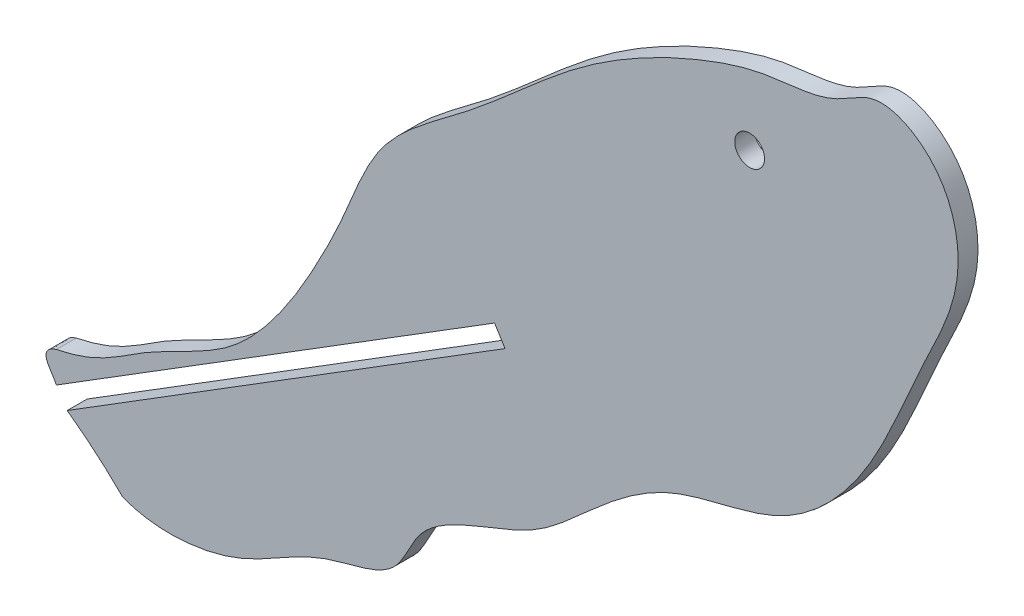
from build123d import *

# Parameters (mm, degrees)
SKETCH1_R           = 2.38125
BOSS_EXTRUDE1_DEPTH = 3.175
CUT_EXTRUDE1_DEPTH  = 3.175


with BuildPart() as part:
    # Sketch1 → Boss-Extrude1 (new body)
    with BuildSketch(Plane.XY):
        with BuildLine():
            Line((40.768145846, 184.453070522), (114.077670793, 230.086665302))
            Line((114.077670793, 230.086665302), (115.755527017, 227.39122035))
            Line((115.755527017, 227.39122035), (43.521756826, 182.427259654))
            add(Edge.make_bspline(
                [(43.521756826, 182.427259654), (44.788750383, 181.76328753), (48.126533854, 180.605526569), (53.705045382, 175.728575889), (63.322367412, 174.351807674), (75.455253783, 177.048714089), (85.407788399, 184.743599328), (98.380090093, 186.107930878), (101.467051899, 195.524505013), (109.919319881, 200.514587774), (120.665380591, 203.617021345), (130.41927408, 213.061934574), (142.549134866, 222.570268935), (160.393689469, 224.081902494), (174.64130148, 238.852254234), (181.053723681, 256.586171695), (190.156058618, 272.865915288), (186.171272479, 287.724417804), (175.242212468, 293.103052821), (167.541303275, 286.786726967), (157.728162565, 286.776771149), (143.796374698, 282.153767947), (126.785607672, 272.999703707), (111.702283177, 257.849735431), (95.369574235, 247.282489302), (90.600838496, 233.821235853), (85.069000572, 222.63671104), (79.332350325, 213.030247768), (70.563493008, 203.671709206), (58.088145357, 198.920146383), (49.8665511, 191.787864635), (36.752245231, 190.436464275), (39.518833147, 185.745298556), (40.768145846, 184.453070522)],
                knots=[0, 0, 0, 0, 0.010738041, 0.027613768, 0.05370555, 0.080470068, 0.119119449, 0.14868445, 0.166041763, 0.187193333, 0.219521226, 0.249444867, 0.287922407, 0.333236135, 0.377488775, 0.432665243, 0.47672388, 0.512866446, 0.536093959, 0.553131728, 0.581565299, 0.607650885, 0.663372441, 0.724739812, 0.769453903, 0.804289374, 0.828954558, 0.863970513, 0.888092373, 0.924484508, 0.959068524, 0.980197156, 0.991940329, 0.991940329, 0.991940329, 0.991940329], degree=3))
        make_face()
        with Locations((154.849064279, 274.384345548)):
            Circle(SKETCH1_R, mode=Mode.SUBTRACT)
    extrude(amount=BOSS_EXTRUDE1_DEPTH)

    # Sketch2 → Cut-Extrude1 (cut)
    with BuildSketch(Plane.XY.offset(3.175)):
        with BuildLine():
            Line((44.039148812, 191.407071505), (42.390364395, 195.382166878))
            Line((42.390364395, 195.382166878), (32.999363682, 190.122955358))
            Line((32.999363682, 190.122955358), (39.413569446, 174.65878709))
            Line((39.413569446, 174.65878709), (53.23570287, 172.389760105))
            Line((53.23570287, 172.389760105), (54.65129508, 176.265765907))
            add(Edge.make_bspline(
                [(54.65129508, 176.265765907), (50.511854548, 180.40573942), (45.769955095, 183.826714484)],
                knots=[0, 0, 0, 1, 1, 1], degree=2))
            Line((45.769955095, 183.826714484), (44.039148812, 186.48919917))
            add(Edge.make_bspline(
                [(44.039148812, 186.48919917), (43.31274665, 188.083473633), (40.700514229, 190.310137173), (44.039148812, 191.407071505)],
                knots=[0, 0, 0, 0, 1, 1, 1, 1], degree=3))
        make_face()
    extrude(amount=-CUT_EXTRUDE1_DEPTH, mode=Mode.SUBTRACT)


solid = part.part
